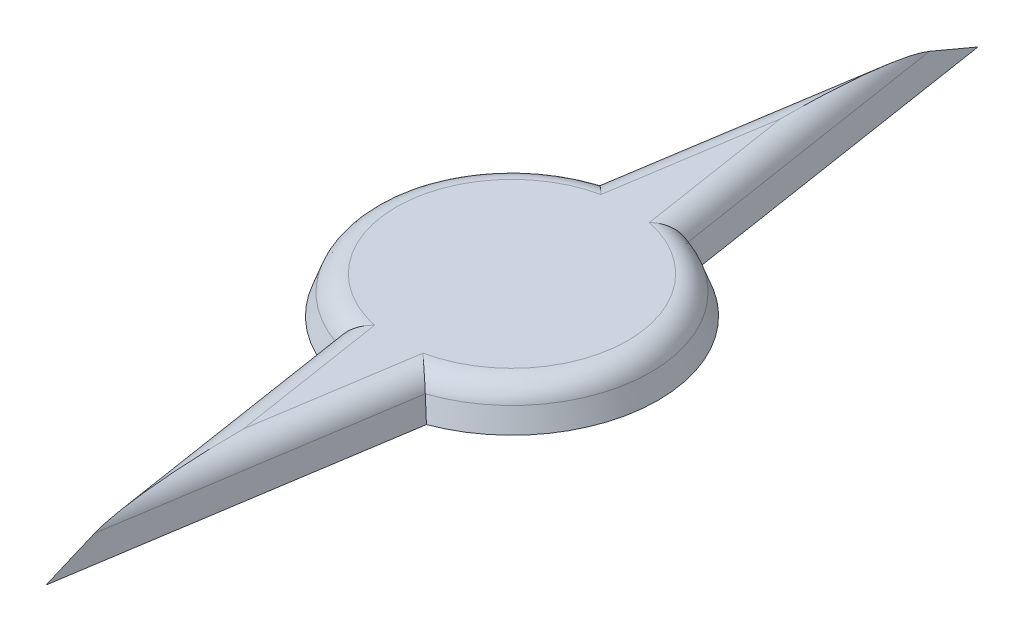
from build123d import *

# Parameters (mm, degrees)
BOSS_EXTRUDE1_DEPTH = 1.5
BOSS_EXTRUDE1_DRAFT = 20
FILLET1_R           = 1


with BuildPart() as part:
    # Sketch1 → Boss-Extrude1 (with draft: the straight prism first)
    with BuildSketch(Plane(origin=(0, 0, 0), x_dir=(1, 0, 0), z_dir=(0, 1, 0))):
        with BuildLine():
            Line((2.105043255, 5.618611296), (0, 19.137920482))
            Line((0, 19.137920482), (-2.105043255, 5.618611296))
            ThreePointArc((-2.105043255, 5.618611296), (-6, 0), (-2.105043255, -5.618611296))
            Line((-2.105043255, -5.618611296), (0, -19.137920482))
            Line((0, -19.137920482), (2.105043255, -5.618611296))
            ThreePointArc((2.105043255, -5.618611296), (6, 0), (2.105043255, 5.618611296))
        make_face()
    extrude(amount=BOSS_EXTRUDE1_DEPTH)
    # Boss-Extrude1: the draft: its side faces are tilted about the plane it starts from
    boss_extrude1_sides = [part.faces().sort_by_distance(p)[0] for p in [
        (1.052521627, 0.75, -12.378265889),
        (-1.052521627, 0.75, -12.378265889),
        (-6, 0.75, 0),
        (-1.052521627, 0.75, 12.378265889),
        (1.052521627, 0.75, 12.378265889),
        (6, 0.75, 0),
    ]]
    draft(boss_extrude1_sides, Plane(origin=(0, 0, 0), x_dir=(1, 0, 0), z_dir=(0, 1, 0)), BOSS_EXTRUDE1_DRAFT)

    # Fillet1
    fillet1_edges = [part.edges().sort_by_distance(p)[0] for p in [
        (-0.80814003, 1.5, 10.399206057),
        (-5.454044649, 1.5, 0),
        (-0.80814003, 1.5, -10.399206057),
        (0.80814003, 1.5, -10.399206057),
        (5.454044649, 1.5, 0),
        (0.80814003, 1.5, 10.399206057),
    ]]
    fillet(fillet1_edges, radius=FILLET1_R)


solid = part.part
